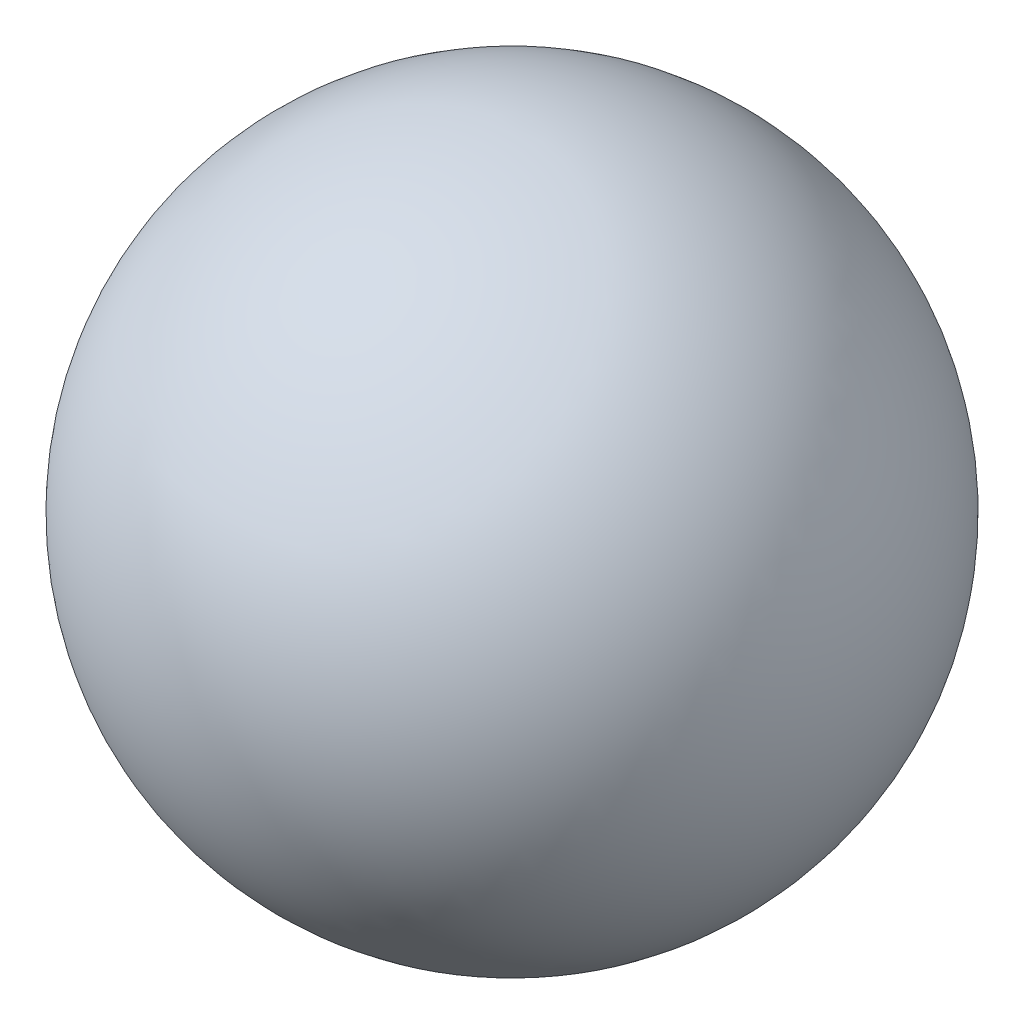
from build123d import *

# Parameters (mm, degrees)
CUT_EXTRUDE1_DEPTH      = 3
CUT_EXTRUDE1_DEPTH_BACK = 35.641016151
SKETCH2_R               = 3.96875


with BuildPart() as part:
    # Sketch1 → Revolve1 (revolve)
    with BuildSketch(Plane(origin=(0, 0, 0), x_dir=(0, 0, -1), z_dir=(1, 0, 0))):
        with BuildLine():
            Line((0, 20), (0, -20))
            ThreePointArc((0, -20), (20, 0), (0, 20))
        make_face()
    revolve(axis=Axis((0, 20, 0), (0, -1, 0)))

    # Sketch2 → Cut-Extrude1 (cut, two sides: drawn at the far end of the back side and taken through both)
    with BuildSketch(Plane(origin=(0, 0, 0), x_dir=(1, 0, 0), z_dir=(0, 1, 0)).offset(-CUT_EXTRUDE1_DEPTH_BACK)):
        Circle(SKETCH2_R)
    extrude(amount=CUT_EXTRUDE1_DEPTH + CUT_EXTRUDE1_DEPTH_BACK, mode=Mode.SUBTRACT)


solid = part.part
